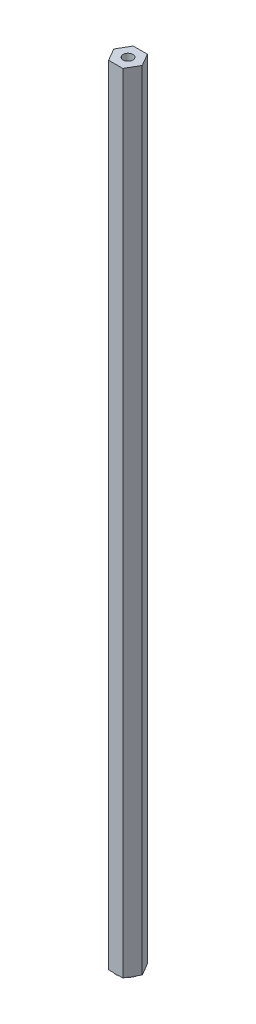
from build123d import *

# Parameters (mm, degrees)
BOSS_EXTRUDE1_DEPTH = 406.4
SKETCH2_R           = 2.54
CUT_EXTRUDE1_DEPTH  = 25.4
SKETCH3_R           = 6.35
BOSS_EXTRUDE2_DEPTH = 0.254


with BuildPart() as part:
    # Sketch1 → Boss-Extrude1 (new body)
    with BuildSketch(Plane(origin=(0, 0, 0), x_dir=(1, 0, 0), z_dir=(0, 1, 0))):
        Polygon((7.332348419, 0), (3.666174209, 6.35), (-3.666174209, 6.35), (-7.332348419, 0), (-3.666174209, -6.35), (3.666174209, -6.35), align=None)
    extrude(amount=BOSS_EXTRUDE1_DEPTH)

    # Sketch2 → Cut-Extrude1 (cut)
    with BuildSketch(Plane(origin=(0, 406.4, 0), x_dir=(1, 0, 0), z_dir=(0, 1, 0))):
        Circle(SKETCH2_R)
    extrude(amount=-CUT_EXTRUDE1_DEPTH, mode=Mode.SUBTRACT)

    # Sketch3 → Boss-Extrude2 (add)
    with BuildSketch(Plane.XZ):
        Circle(SKETCH3_R)
    extrude(amount=BOSS_EXTRUDE2_DEPTH)


solid = part.part
